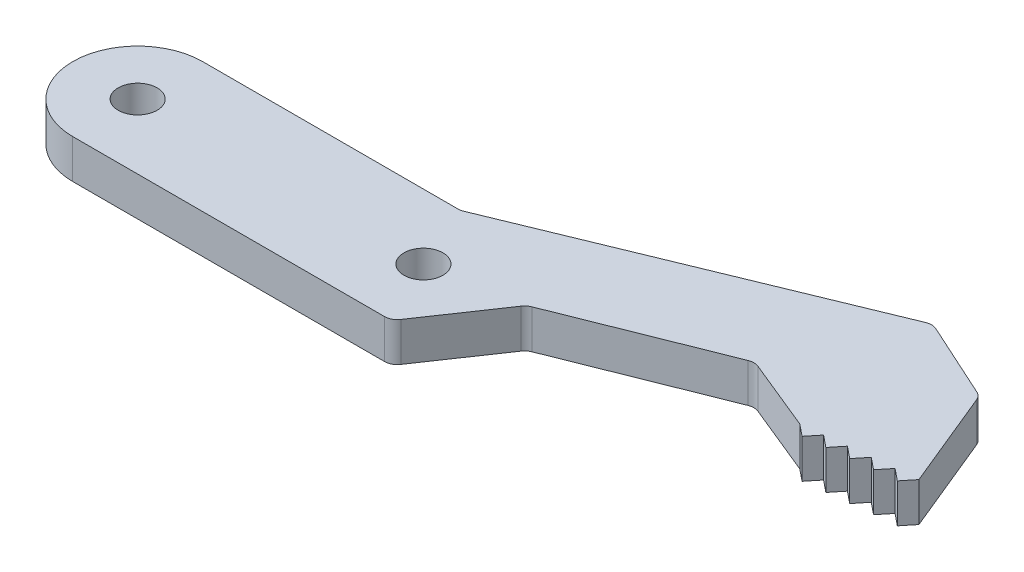
from build123d import *

# Parameters (mm, degrees)
SKETCH1_R           = 1.5
BOSS_EXTRUDE1_DEPTH = 3


with BuildPart() as part:
    # Sketch1 → Boss-Extrude1 (new body)
    with BuildSketch(Plane(origin=(0, 0, 0), x_dir=(1, 0, 0), z_dir=(0, 1, 0))):
        with BuildLine():
            Line((0, -5), (23.998875872, -5))
            ThreePointArc((23.998875872, -5), (24.467345461, -4.883479623), (24.826642543, -4.561072489))
            Line((24.826642543, -4.561072489), (28.564941326, 0.954149161))
            ThreePointArc((28.564941326, 0.954149161), (28.766036178, 1.172359953), (29.022312673, 1.321950886))
            Line((29.022312673, 1.321950886), (40.929553216, 6.070049343))
            ThreePointArc((40.929553216, 6.070049343), (41.304486381, 6.141164834), (41.678758689, 6.066649533))
            Line((41.678758689, 6.066649533), (47.144586244, 3.829406729))
            Line((47.144586244, 3.829406729), (48.06174016, 3.086958957))
            Line((48.06174016, 3.086958957), (48.804187932, 4.004112872))
            Line((48.804187932, 4.004112872), (49.721341848, 3.2616651))
            Line((49.721341848, 3.2616651), (50.46378962, 4.178819016))
            Line((50.46378962, 4.178819016), (51.380943536, 3.436371244))
            Line((51.380943536, 3.436371244), (52.123391308, 4.35352516))
            Line((52.123391308, 4.35352516), (53.040545224, 3.611077387))
            Line((53.040545224, 3.611077387), (53.782992996, 4.528231303))
            Line((53.782992996, 4.528231303), (54.700146912, 3.785783531))
            Line((54.700146912, 3.785783531), (55.442594685, 4.702937447))
            Line((55.442594685, 4.702937447), (52.341745918, 12.244834503))
            ThreePointArc((52.341745918, 12.244834503), (52.137055639, 12.558350103), (51.831402108, 12.774604725))
            Line((51.831402108, 12.774604725), (46.024183924, 15.419882568))
            ThreePointArc((46.024183924, 15.419882568), (45.628323444, 15.509674561), (45.229386093, 15.434727162))
            Line((45.229386093, 15.434727162), (20.032711481, 5.075121772))
            ThreePointArc((20.032711481, 5.075121772), (19.846254378, 5.018960187), (19.652448068, 5))
            Line((19.652448068, 5), (0, 5))
            ThreePointArc((0, 5), (-5, 0), (0, -5))
        make_face()
        Circle(SKETCH1_R, mode=Mode.SUBTRACT)
        with Locations((22, 0)):
            Circle(SKETCH1_R, mode=Mode.SUBTRACT)
    extrude(amount=BOSS_EXTRUDE1_DEPTH)


solid = part.part
